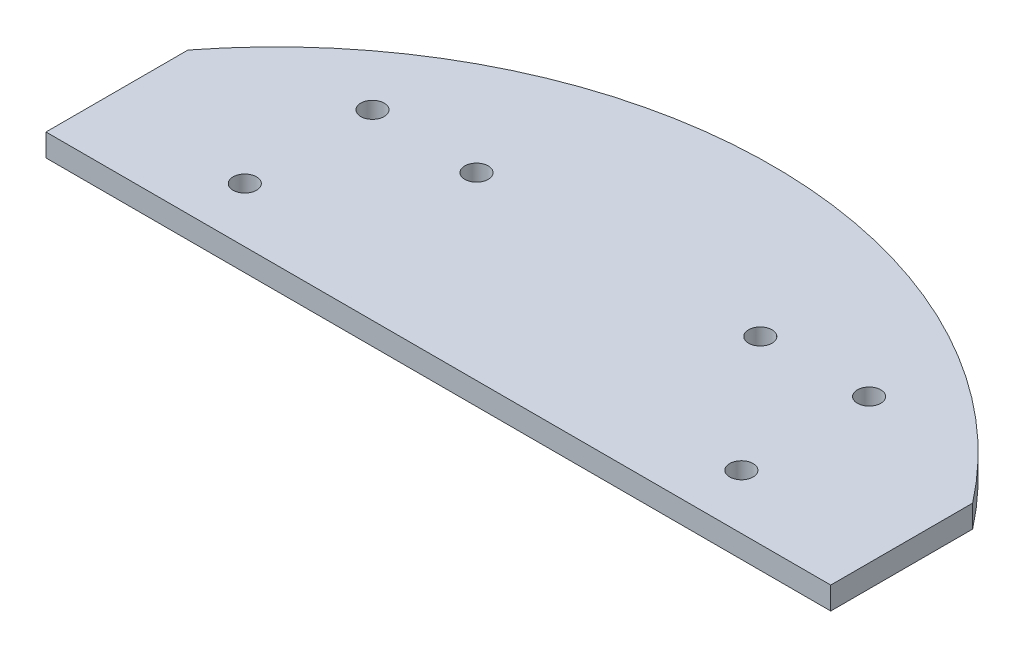
from build123d import *

# Parameters (mm, degrees)
SKETCH1_R           = 1.65
BOSS_EXTRUDE2_DEPTH = 3.175


with BuildPart() as part:
    # Sketch1 → Boss-Extrude2 (new body)
    with BuildSketch(Plane(origin=(0, 0, 0), x_dir=(1, 0, 0), z_dir=(0, 1, 0))):
        with BuildLine():
            Line((-55.306734792, 42.908799641), (-55.306734792, 22.908799641))
            Line((-55.306734792, 22.908799641), (55.306734792, 22.908799641))
            Line((55.306734792, 22.908799641), (55.306734792, 42.908799641))
            ThreePointArc((55.306734792, 42.908799641), (0, 70), (-55.306734792, 42.908799641))
        make_face()
        with Locations((35, 48.621778265)):
            Circle(SKETCH1_R, mode=Mode.SUBTRACT)
        with Locations((35, 30.621778265)):
            Circle(SKETCH1_R, mode=Mode.SUBTRACT)
        with Locations((-35, 30.621778265)):
            Circle(SKETCH1_R, mode=Mode.SUBTRACT)
        with Locations((-35, 48.621778265)):
            Circle(SKETCH1_R, mode=Mode.SUBTRACT)
        with Locations((20, 48.284271247)):
            Circle(SKETCH1_R, mode=Mode.SUBTRACT)
        with Locations((-20, 48.284271247)):
            Circle(SKETCH1_R, mode=Mode.SUBTRACT)
    extrude(amount=BOSS_EXTRUDE2_DEPTH)


solid = part.part
